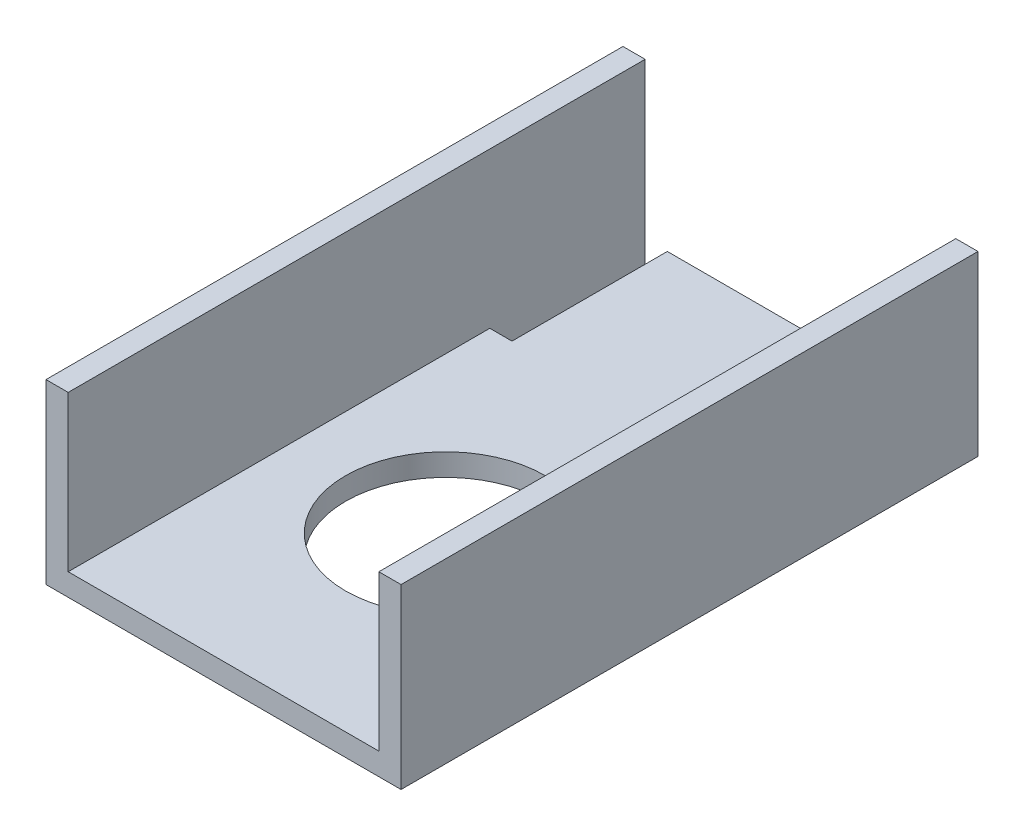
from build123d import *

# Parameters (mm, degrees)
BOSS_EXTRUDE1_DEPTH = 82.55
CUT_EXTRUDE1_REACH  = 27.4
SKETCH2_R           = 14.2875
CUT_EXTRUDE2_REACH  = 5.175
SKETCH3_W           = 3.175
SKETCH3_H           = 22.225


with BuildPart() as part:
    # Sketch1 → Boss-Extrude1 (new body)
    with BuildSketch(Plane.XY):
        Polygon((47.625, 3.175), (47.625, 25.4), (50.8, 25.4), (50.8, 0), (0, 0), (0, 25.4), (3.175, 25.4), (3.175, 3.175), align=None)
    extrude(amount=BOSS_EXTRUDE1_DEPTH)

    # Sketch2 → Cut-Extrude1 (cut, up to next)
    with BuildSketch(Plane.XZ, mode=Mode.PRIVATE) as cut_extrude1_sk1:
        with Locations((25.4, 50.8)):
            Circle(SKETCH2_R)
    cut_extrude1_tool1 = extrude(cut_extrude1_sk1.sketch, amount=-CUT_EXTRUDE1_REACH, mode=Mode.PRIVATE) & part.part
    add(cut_extrude1_tool1.solids().sort_by_distance((25.4, 0, 50.8))[0], mode=Mode.SUBTRACT)

    # Sketch3 → Cut-Extrude2 (cut, up to next)
    with BuildSketch(Plane(origin=(0, 3.175, 0), x_dir=(1, 0, 0), z_dir=(0, 1, 0)), mode=Mode.PRIVATE) as cut_extrude2_sk1:
        with Locations((4.7625, -11.1125)):
            Rectangle(SKETCH3_W, SKETCH3_H)
    cut_extrude2_tool1 = extrude(cut_extrude2_sk1.sketch, amount=-CUT_EXTRUDE2_REACH, mode=Mode.PRIVATE) & part.part
    add(cut_extrude2_tool1.solids().sort_by_distance((4.7625, 3.175, 11.1125))[0], mode=Mode.SUBTRACT)


solid = part.part
